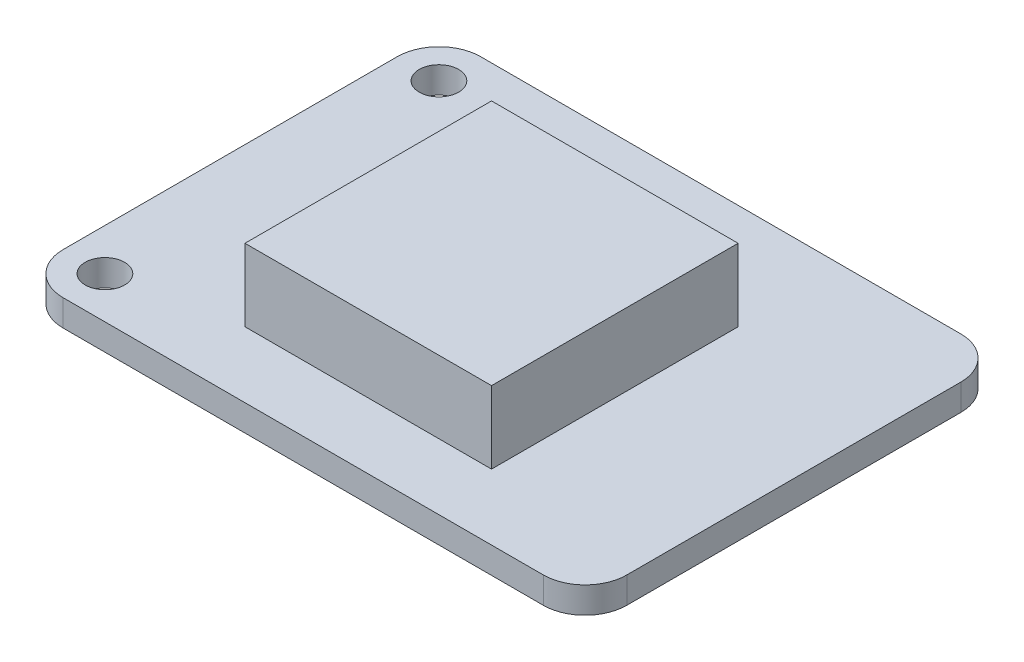
from build123d import *

# Parameters (mm, degrees)
PCB_DEPTH            = 1.6
M2_CLEARANCE_HOLE1_D = 2.4
SKETCH4_W            = 15
SKETCH4_H            = 15
ANTENNA_DEPTH        = 4.4
SKETCH5_R            = 6.5
BATTERY_HOLDER_DEPTH = 3.5


with BuildPart() as part:
    # Sketch1 → PCB (new body)
    with BuildSketch(Plane(origin=(0, 0, 0), x_dir=(1, 0, 0), z_dir=(0, 1, 0))):
        with BuildLine():
            Line((-14.605, -12.7), (14.605, -12.7))
            ThreePointArc((14.605, -12.7), (16.401051224, -11.956051224), (17.145, -10.16))
            Line((17.145, -10.16), (17.145, 10.16))
            ThreePointArc((17.145, 10.16), (16.401051224, 11.956051224), (14.605, 12.7))
            Line((14.605, 12.7), (-14.605, 12.7))
            ThreePointArc((-14.605, 12.7), (-16.401051224, 11.956051224), (-17.145, 10.16))
            Line((-17.145, 10.16), (-17.145, -10.16))
            ThreePointArc((-17.145, -10.16), (-16.401051224, -11.956051224), (-14.605, -12.7))
        make_face()
    extrude(amount=PCB_DEPTH)

    # M2 Clearance Hole1 (through all)
    with Locations(Plane(origin=(0, 1.6, 0), x_dir=(1, 0, 0), z_dir=(0, 1, 0))):
        with Locations((-14.605, -10.16), (-14.605, 10.16)):
            Hole(M2_CLEARANCE_HOLE1_D / 2)

    # Sketch4 → Antenna (add)
    with BuildSketch(Plane(origin=(0, 1.6, 0), x_dir=(1, 0, 0), z_dir=(0, 1, 0))):
        with Locations((-0.045, -1.2)):
            Rectangle(SKETCH4_W, SKETCH4_H)
    extrude(amount=ANTENNA_DEPTH)

    # Sketch5 → Battery Holder (add)
    with BuildSketch(Plane.XZ):
        with Locations((-9.645, 0)):
            Circle(SKETCH5_R)
    extrude(amount=BATTERY_HOLDER_DEPTH)


solid = part.part
